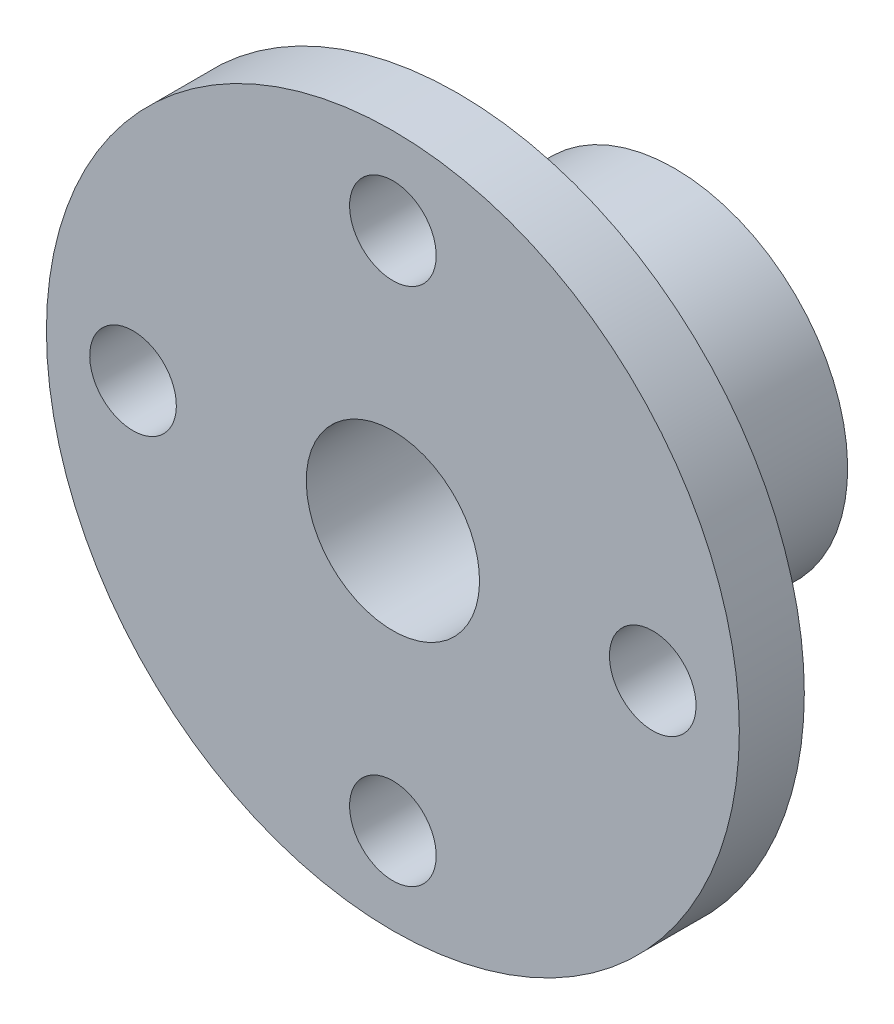
from build123d import *

# Parameters (mm, degrees)
SKETCH1_R             = 16
SKETCH1_R_2           = 4
SKETCH1_R_3           = 2
BOSS_EXTRUDE1_DEPTH   = 3
SKETCH2_R             = 8
SKETCH2_R_2           = 4
BOSS_EXTRUDE2_DEPTH   = 13
BODY_MOVE_COPY1_ANGLE = 90


with BuildPart() as part:
    # Sketch1 → Boss-Extrude1 (new body)
    with BuildSketch(Plane(origin=(0, 0, 0), x_dir=(1, 0, 0), z_dir=(0, 1, 0))):
        Circle(SKETCH1_R)
        Circle(SKETCH1_R_2, mode=Mode.SUBTRACT)
        with Locations((12, 0)):
            Circle(SKETCH1_R_3, mode=Mode.SUBTRACT)
        with Locations((0, -12)):
            Circle(SKETCH1_R_3, mode=Mode.SUBTRACT)
        with Locations((-12, 0)):
            Circle(SKETCH1_R_3, mode=Mode.SUBTRACT)
        with Locations((0, 12)):
            Circle(SKETCH1_R_3, mode=Mode.SUBTRACT)
    extrude(amount=BOSS_EXTRUDE1_DEPTH)

    # Sketch2 → Boss-Extrude2 (add)
    with BuildSketch(Plane(origin=(0, 0, 0), x_dir=(1, 0, 0), z_dir=(0, 1, 0))):
        Circle(SKETCH2_R)
        Circle(SKETCH2_R_2, mode=Mode.SUBTRACT)
    extrude(amount=BOSS_EXTRUDE2_DEPTH)


with BuildPart() as part_1:
    # Body-Move/Copy1: moved
    add(part.part.rotate(Axis((0, 6.5, 0), (-1, 0, 0)), BODY_MOVE_COPY1_ANGLE))


solid = part_1.part
